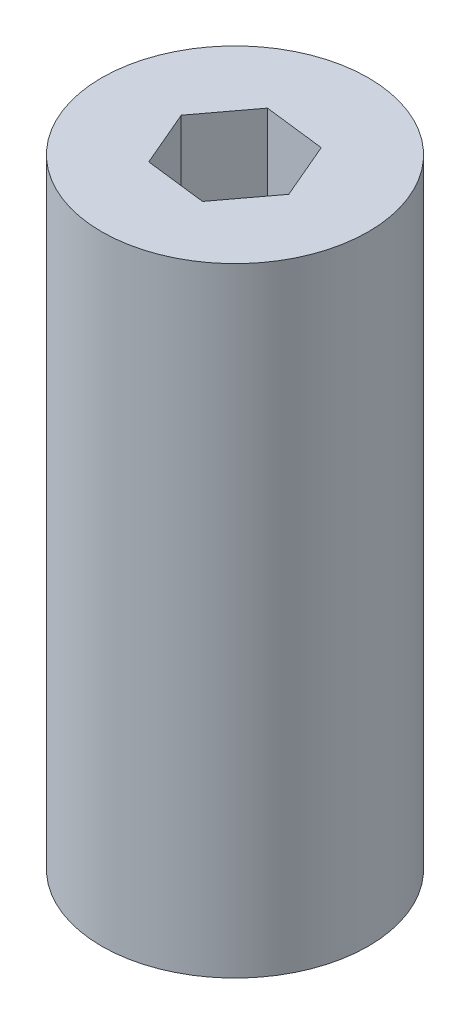
from build123d import *

# Parameters (mm, degrees)
SKETCH1_R           = 15.875
BOSS_EXTRUDE1_DEPTH = 73.66


with BuildPart() as part:
    # Sketch1 → Boss-Extrude1 (new body)
    with BuildSketch(Plane(origin=(0, 0, 0), x_dir=(1, 0, 0), z_dir=(0, 1, 0))):
        Circle(SKETCH1_R)
        Polygon((4.399409051, 5.865878735), (-2.880295474, 6.742939367), (-7.279704526, 0.877060633), (-4.399409051, -5.865878735), (2.880295474, -6.742939367), (7.279704526, -0.877060633), align=None, mode=Mode.SUBTRACT)
    extrude(amount=BOSS_EXTRUDE1_DEPTH)


solid = part.part
